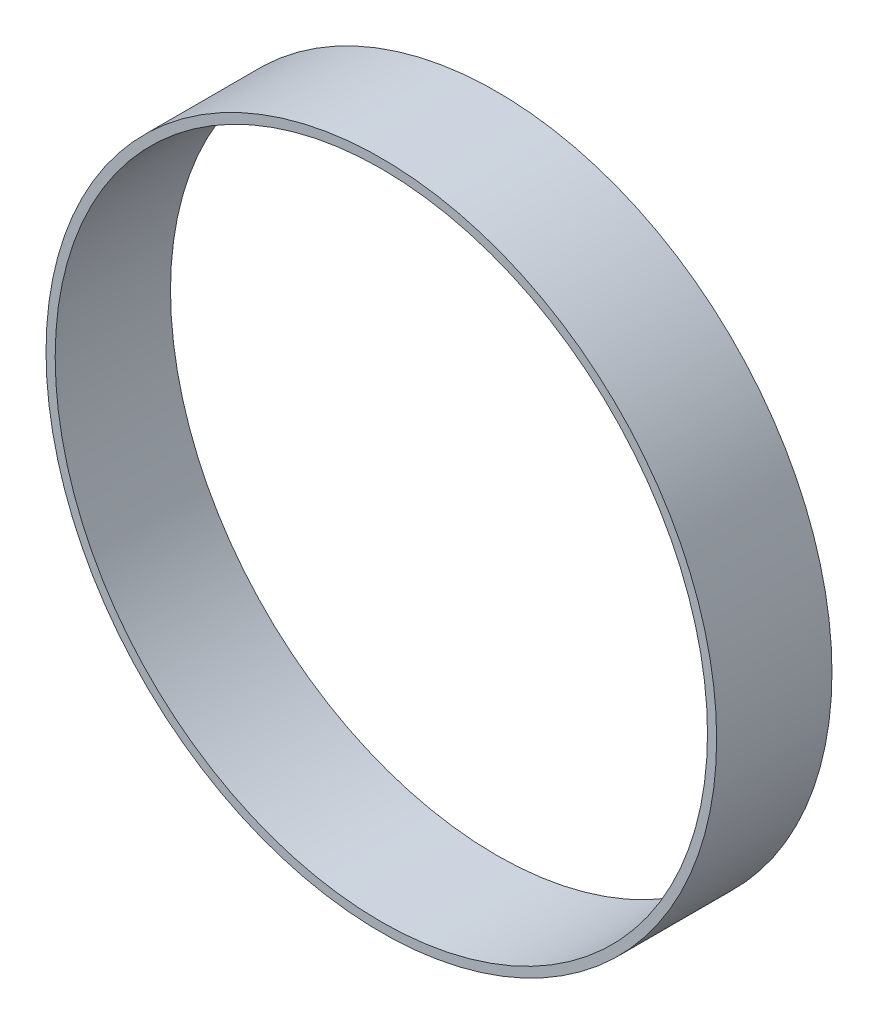
from build123d import *

# Parameters (mm, degrees)
SKETCH1_R           = 29.075
SKETCH1_R_2         = 28.28125
BOSS_EXTRUDE1_DEPTH = 5


with BuildPart() as part:
    # Sketch1 → Boss-Extrude1 (new body, symmetric)
    with BuildSketch(Plane.XY):
        Circle(SKETCH1_R)
        Circle(SKETCH1_R_2, mode=Mode.SUBTRACT)
    extrude(amount=BOSS_EXTRUDE1_DEPTH, both=True)


solid = part.part
